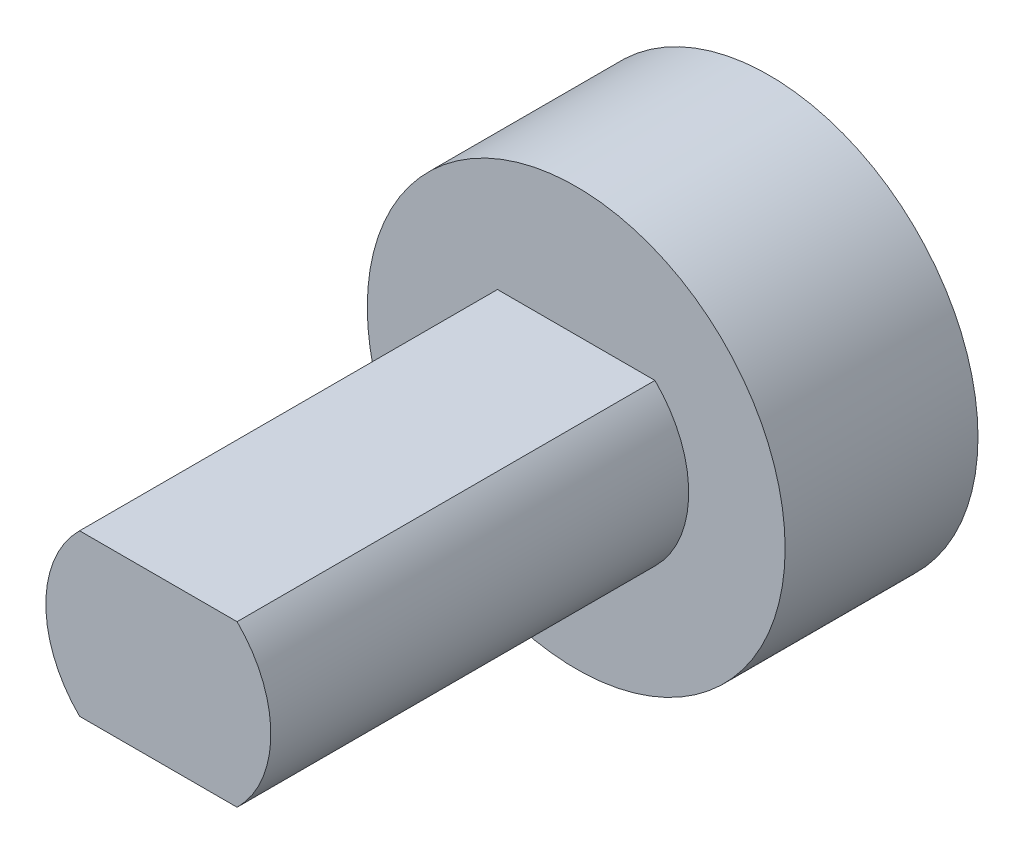
from build123d import *

# Parameters (mm, degrees)
SKETCH1_R           = 6.5
BOSS_EXTRUDE1_DEPTH = 6
BOSS_EXTRUDE2_DEPTH = 13
SKETCH3_R           = 1.5875
CUT_EXTRUDE1_DEPTH  = 10


with BuildPart() as part:
    # Sketch1 → Boss-Extrude1 (new body)
    with BuildSketch(Plane.XY):
        Circle(SKETCH1_R)
    extrude(amount=BOSS_EXTRUDE1_DEPTH)

    # Sketch2 → Boss-Extrude2 (add)
    with BuildSketch(Plane.XY.offset(6)):
        with BuildLine():
            Line((-2.449489743, 2.5), (2.449489743, 2.5))
            ThreePointArc((2.449489743, 2.5), (3.5, 0), (2.449489743, -2.5))
            Line((2.449489743, -2.5), (-2.449489743, -2.5))
            ThreePointArc((-2.449489743, -2.5), (-3.5, 0), (-2.449489743, 2.5))
        make_face()
    extrude(amount=BOSS_EXTRUDE2_DEPTH)

    # Sketch3 → Cut-Extrude1 (cut)
    with BuildSketch(Plane(origin=(0, 0, 0), x_dir=(-1, 0, 0), z_dir=(0, 0, -1))):
        Circle(SKETCH3_R)
    extrude(amount=-CUT_EXTRUDE1_DEPTH, mode=Mode.SUBTRACT)


solid = part.part
